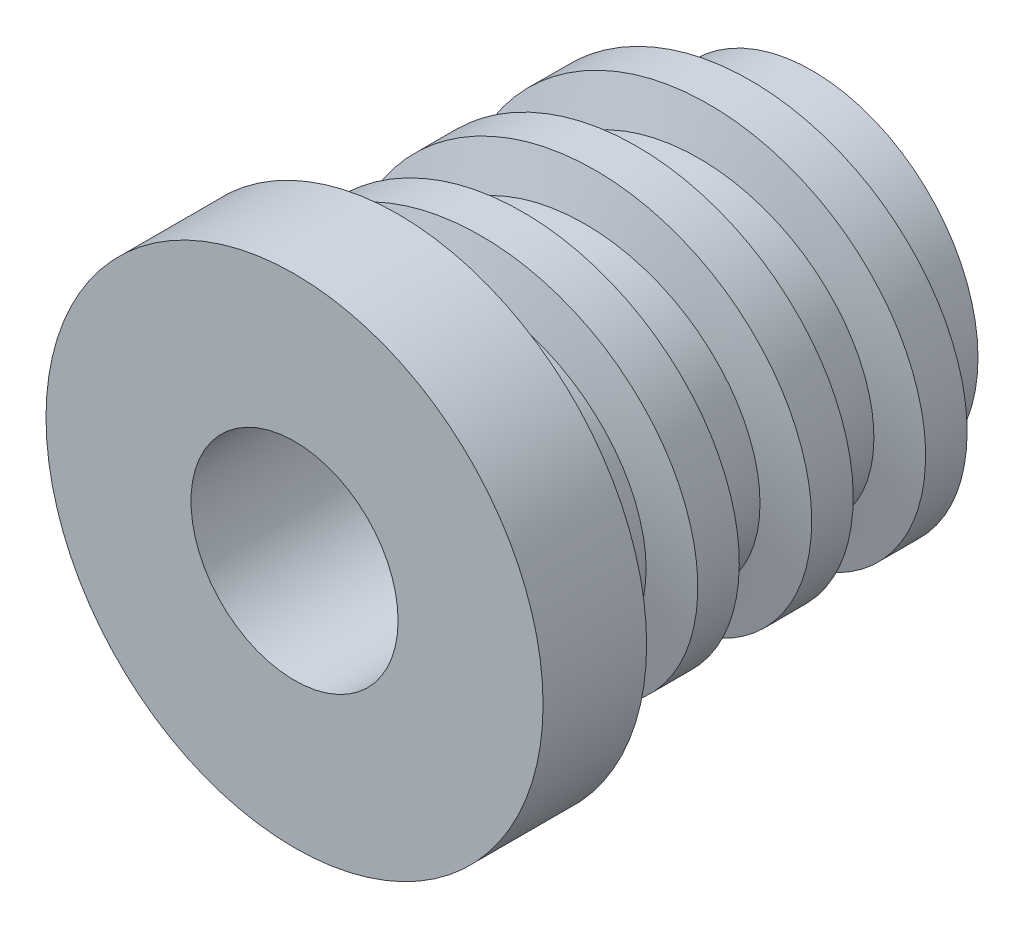
from build123d import *

# Parameters (mm, degrees)
SKETCH_5_R               = 8
EXTRUDE_3_DEPTH          = 20
SKETCH_7_R               = 12
EXTRUDE_4_DEPTH          = 5
SWEEP_2_PITCH            = 5.5
SWEEP_2_HEIGHT           = 22
SWEEP_2_RADIUS           = 8
SWEEP_2_START_ANGLE      = -135
SKETCH_9_R               = 5
CUT_EXTRUDE_1_DEPTH      = 5
CUT_EXTRUDE_1_DEPTH_BACK = 35


with BuildPart() as part:
    # 草图5 → 凸台-拉伸3 (new body)
    with BuildSketch(Plane.XY):
        Circle(SKETCH_5_R)
    extrude(amount=EXTRUDE_3_DEPTH)

    # 草图7 → 凸台-拉伸4 (add)
    with BuildSketch(Plane.XY.offset(20)):
        Circle(SKETCH_7_R)
    extrude(amount=EXTRUDE_4_DEPTH)

    # 草图9 → 切除-拉伸1 (cut, two sides)
    with BuildSketch(Plane.XY.offset(25)) as cut_extrude_1_sk:
        Circle(SKETCH_9_R)
    extrude(amount=CUT_EXTRUDE_1_DEPTH, mode=Mode.SUBTRACT)
    extrude(cut_extrude_1_sk.sketch, amount=-CUT_EXTRUDE_1_DEPTH_BACK, mode=Mode.SUBTRACT)


with BuildPart() as body_2:
    # 扫描2: sweep along a helix
    with BuildLine() as sweep_2_path:
        add(Helix(SWEEP_2_PITCH, SWEEP_2_HEIGHT, SWEEP_2_RADIUS, center=(0, 0, 0), direction=(0, 0, 1), mode=Mode.PRIVATE).rotate(Axis((0, 0, 0), (0, 0, 1)), SWEEP_2_START_ANGLE))
    # 草图8 → 扫描2 (sweep)
    with BuildSketch(Plane(origin=(-5.656854249, -5.656854249, 0), x_dir=(0.076911889, -0.076911889, -0.994066961), z_dir=(0.702911489, -0.702911489, 0.108769836))):
        Polygon((0, 0), (-3, 0), (-2.5, -2), (-0.5, -2), align=None)
    sweep(path=sweep_2_path.line, is_frenet=True)


solid = Compound([part.part, body_2.part])
